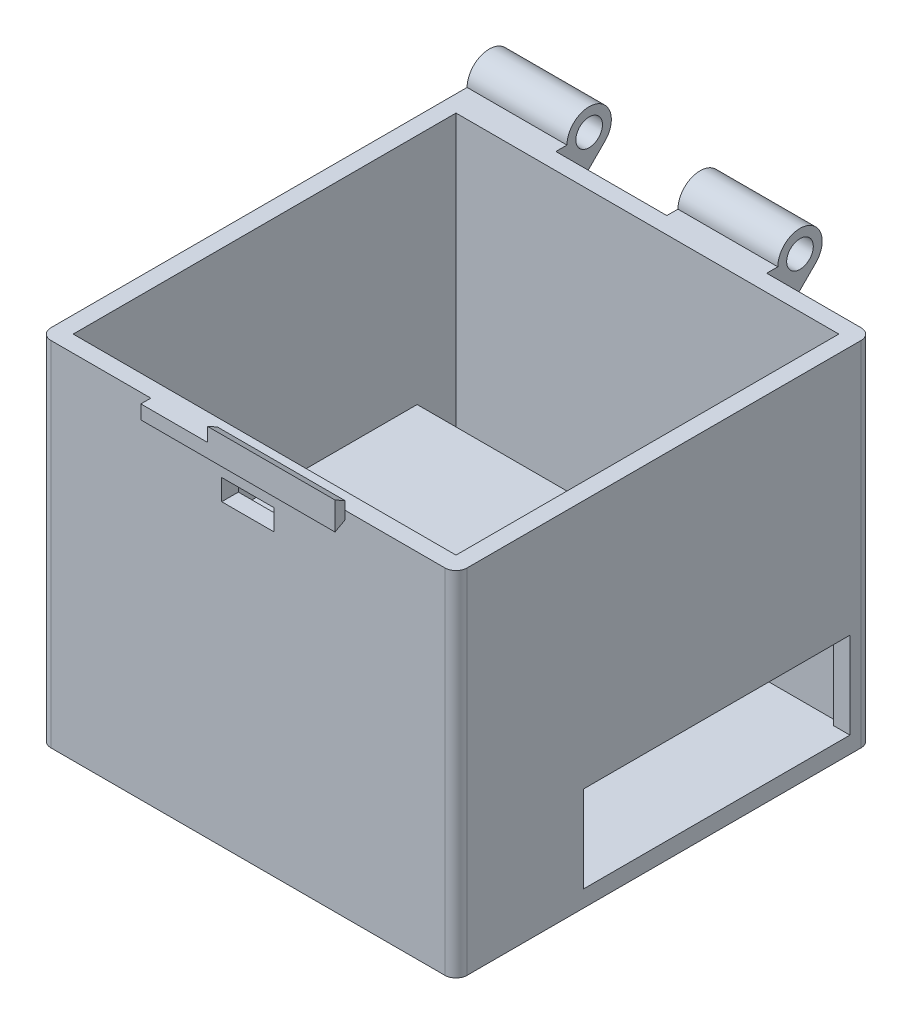
from build123d import *

# Parameters (mm, degrees)
SKETCH1_W               = 95.25
SKETCH1_H               = 95.25
BOSS_EXTRUDE1_DEPTH     = 57.15
SHELL1_T                = -3.81
SKETCH2_R               = 3.048
BOSS_EXTRUDE2_DEPTH     = 22.86
BOSS_EXTRUDE3_START     = -24.13
SKETCH5_R               = 3.048
BOSS_EXTRUDE3_DEPTH     = 22.86
SKETCH6_W               = 11.999999876
SKETCH6_H               = 4.800000052
CUT_EXTRUDE1_DEPTH      = 3.81
BOSS_EXTRUDE4_DEPTH     = 19.812
SKETCH9_W               = 95.25
SKETCH9_H               = 3.81
BOSS_EXTRUDE5_DEPTH     = 95.25
SKETCH10_W              = 87.63
SKETCH10_H              = 8.89
CUT_EXTRUDE2_DEPTH      = 23.622
SKETCH11_W              = 87.63
SKETCH11_H              = 8.89
CUT_EXTRUDE3_DEPTH      = 23.622
FILLET1_R               = 2.54
BOSS_EXTRUDE6_START     = -47.625
BOSS_EXTRUDE6_DEPTH     = 22.225
CUT_EXTRUDE4_DEPTH      = 1
CUT_EXTRUDE4_DEPTH_BACK = 3.81


with BuildPart() as part:
    # Sketch1 → Boss-Extrude1 (new body)
    with BuildSketch(Plane(origin=(0, 0, 0), x_dir=(1, 0, 0), z_dir=(0, 1, 0))):
        Rectangle(SKETCH1_W, SKETCH1_H)
    extrude(amount=BOSS_EXTRUDE1_DEPTH)

    # Shell1
    shell1_openings = [part.faces().sort_by_distance(p)[0] for p in [
        (0, 57.15, 0),
    ]]
    offset(amount=SHELL1_T, openings=shell1_openings, kind=Kind.INTERSECTION)

    # Sketch2 → Boss-Extrude2 (add)
    with BuildSketch(Plane.ZY.offset(47.625)):
        with BuildLine():
            ThreePointArc((-50.165, 57.15), (-57.189031836, 61.843308025), (-58.837102448, 53.557897552))
            Line((-58.837102448, 53.557897552), (-47.625, 42.345795103))
            Line((-47.625, 42.345795103), (-47.625, 57.15))
            Line((-47.625, 57.15), (-50.165, 57.15))
        make_face()
        with Locations((-55.245, 57.15)):
            Circle(SKETCH2_R, mode=Mode.SUBTRACT)
    extrude(amount=-BOSS_EXTRUDE2_DEPTH)

    # Sketch5 → Boss-Extrude3 (add)
    with BuildSketch(Plane(origin=(47.625, 0, 0), x_dir=(0, 0, -1), z_dir=(1, 0, 0)).offset(BOSS_EXTRUDE3_START)):
        with BuildLine():
            Line((50.165, 57.15), (47.625, 57.15))
            Line((47.625, 57.15), (47.625, 42.345795103))
            Line((47.625, 42.345795103), (58.837102448, 53.557897552))
            ThreePointArc((58.837102448, 53.557897552), (57.189031836, 61.843308025), (50.165, 57.15))
        make_face()
        with Locations((55.245, 57.15)):
            Circle(SKETCH5_R, mode=Mode.SUBTRACT)
    extrude(amount=-BOSS_EXTRUDE3_DEPTH)

    # Sketch6 → Cut-Extrude1 (cut)
    with BuildSketch(Plane.XY.offset(47.625)):
        with Locations((0, 47.129999974)):
            Rectangle(SKETCH6_W, SKETCH6_H)
    extrude(amount=-CUT_EXTRUDE1_DEPTH, mode=Mode.SUBTRACT)

    # Sketch8 → Boss-Extrude4 (add)
    with BuildSketch(Plane.XZ):
        Polygon((41.275, -42.545), (-42.545, -42.545), (-42.545, 18.415), (41.275, 18.415), (47.625, 18.415), (47.625, 47.625), (-47.625, 47.625), (-47.625, -47.625), (47.625, -47.625), (47.625, -42.545), align=None)
    extrude(amount=BOSS_EXTRUDE4_DEPTH)

    # Sketch9 → Boss-Extrude5 (add, through all)
    with BuildSketch(Plane(origin=(47.625, 0, 0), x_dir=(0, 0, -1), z_dir=(1, 0, 0))):
        with Locations((0, -21.717)):
            Rectangle(SKETCH9_W, SKETCH9_H)
    extrude(amount=-BOSS_EXTRUDE5_DEPTH)

    # Sketch10 → Cut-Extrude2 (cut)
    with BuildSketch(Plane(origin=(0, 3.81, 0), x_dir=(1, 0, 0), z_dir=(0, 1, 0))):
        with Locations((0, 39.37)):
            Rectangle(SKETCH10_W, SKETCH10_H)
    extrude(amount=-CUT_EXTRUDE2_DEPTH, mode=Mode.SUBTRACT)

    # Sketch11 → Cut-Extrude3 (cut)
    with BuildSketch(Plane(origin=(0, 3.81, 0), x_dir=(1, 0, 0), z_dir=(0, 1, 0))):
        with Locations((0, -13.97)):
            Rectangle(SKETCH11_W, SKETCH11_H)
    extrude(amount=-CUT_EXTRUDE3_DEPTH, mode=Mode.SUBTRACT)

    # Fillet1
    fillet1_edges = [part.edges().sort_by_distance(p)[0] for p in [
        (-47.625, 9.361897552, -47.625),
        (47.625, 16.764, -47.625),
        (47.625, 16.764, 47.625),
        (-47.625, 16.764, 47.625),
    ]]
    fillet(fillet1_edges, radius=FILLET1_R)

    # Sketch12 → Boss-Extrude6 (add, symmetric)
    with BuildSketch(Plane(origin=(47.625, 0, 0), x_dir=(0, 0, -1), z_dir=(1, 0, 0)).offset(BOSS_EXTRUDE6_START)):
        Polygon((-47.625, 55.245), (-47.625, 59.055), (-49.911, 60.325), (-49.911, 53.975), align=None)
    extrude(amount=BOSS_EXTRUDE6_DEPTH, both=True)

    # Sketch13 → Cut-Extrude4 (cut, two sides)
    with BuildSketch(Plane.XY.offset(49.911)) as cut_extrude4_sk:
        Polygon((-245.795957614, 57.15), (-22.225, 57.15), (-6.985, 57.15), (-6.985, 60.325), (-6.985, 283.895957614), (-314.864920178, 608.157961407), (-553.675877792, 381.412003793), align=None)
    extrude(amount=CUT_EXTRUDE4_DEPTH, mode=Mode.SUBTRACT)
    extrude(cut_extrude4_sk.sketch, amount=-CUT_EXTRUDE4_DEPTH_BACK, mode=Mode.SUBTRACT)


solid = part.part
